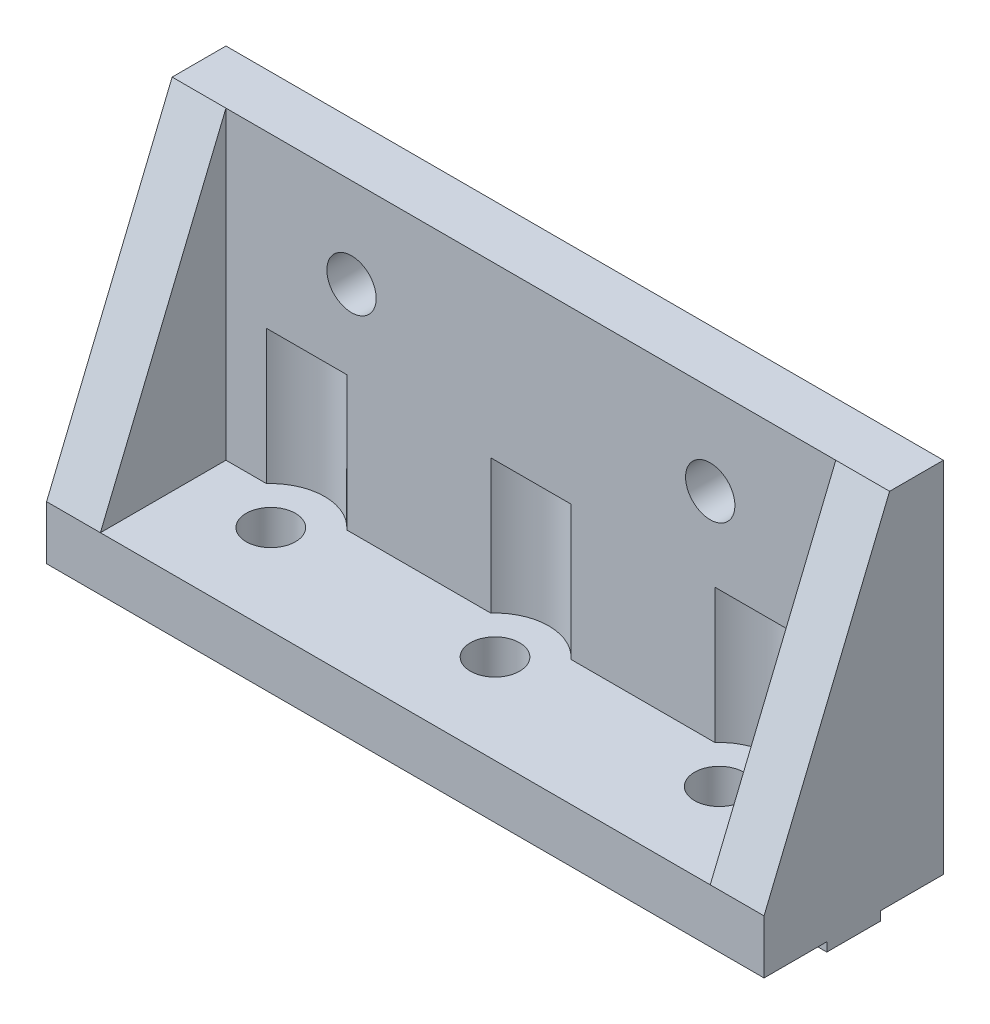
from build123d import *

# Parameters (mm, degrees)
CROQUIS1_W                 = 80
CROQUIS1_H                 = 40
SALIENTE_EXTRUIR1_DEPTH    = 20
CROQUIS2_W                 = 68
CROQUIS2_H                 = 14
CORTAR_EXTRUIR1_DEPTH      = 34
CORTAR_EXTRUIR2_DEPTH      = 80
CORTAR_EXTRUIR3_REACH      = 22
CROQUIS4_R                 = 2.75
CROQUIS8_W                 = 80
CROQUIS8_H                 = 6
SALIENTE_EXTRUIR2_DEPTH    = 1
CROQUIS5_R                 = 2.75
CORTAR_EXTRUIR6_DEPTH      = 2
CORTAR_EXTRUIR6_DEPTH_BACK = 41
CROQUIS9_R                 = 6
CORTAR_EXTRUIR8_DEPTH      = 15


with BuildPart() as part:
    # Croquis1 → Saliente-Extruir1 (new body)
    with BuildSketch(Plane.XY):
        with Locations((40, -20)):
            Rectangle(CROQUIS1_W, CROQUIS1_H)
    extrude(amount=SALIENTE_EXTRUIR1_DEPTH)

    # Croquis2 → Cortar-Extruir1 (cut)
    with BuildSketch(Plane(origin=(0, 0, 0), x_dir=(1, 0, 0), z_dir=(0, 1, 0))):
        with Locations((40, -13)):
            Rectangle(CROQUIS2_W, CROQUIS2_H)
    extrude(amount=-CORTAR_EXTRUIR1_DEPTH, mode=Mode.SUBTRACT)

    # Croquis3 → Cortar-Extruir2 (cut)
    with BuildSketch(Plane.ZY):
        Polygon((20, 0), (20, -34), (6, 0), align=None)
    extrude(amount=-CORTAR_EXTRUIR2_DEPTH, mode=Mode.SUBTRACT)

    # Croquis4 → Cortar-Extruir3 (cut, up to next)
    with BuildSketch(Plane(origin=(0, 0, 0), x_dir=(-1, 0, 0), z_dir=(0, 0, -1)), mode=Mode.PRIVATE) as cortar_extruir3_sk1:
        with Locations((-60, -10)):
            Circle(CROQUIS4_R)
    cortar_extruir3_tool1 = extrude(cortar_extruir3_sk1.sketch, amount=-CORTAR_EXTRUIR3_REACH, mode=Mode.PRIVATE) & part.part
    add(cortar_extruir3_tool1.solids().sort_by_distance((60, -10, 0))[0], mode=Mode.SUBTRACT)
    # Croquis4 → Cortar-Extruir3 (cut, up to next)
    with BuildSketch(Plane(origin=(0, 0, 0), x_dir=(-1, 0, 0), z_dir=(0, 0, -1)), mode=Mode.PRIVATE) as cortar_extruir3_sk2:
        with Locations((-20, -10)):
            Circle(CROQUIS4_R)
    cortar_extruir3_tool2 = extrude(cortar_extruir3_sk2.sketch, amount=-CORTAR_EXTRUIR3_REACH, mode=Mode.PRIVATE) & part.part
    add(cortar_extruir3_tool2.solids().sort_by_distance((20, -10, 0))[0], mode=Mode.SUBTRACT)

    # Croquis8 → Saliente-Extruir2 (add)
    with BuildSketch(Plane.XZ.offset(40)):
        with Locations((40, 10)):
            Rectangle(CROQUIS8_W, CROQUIS8_H)
    extrude(amount=SALIENTE_EXTRUIR2_DEPTH)

    # Croquis5 → Cortar-Extruir6 (cut, two sides)
    with BuildSketch(Plane.XZ.offset(40)) as cortar_extruir6_sk:
        with Locations((15, 10)):
            Circle(CROQUIS5_R)
        with Locations((40, 10)):
            Circle(CROQUIS5_R)
        with Locations((65, 10)):
            Circle(CROQUIS5_R)
    extrude(amount=CORTAR_EXTRUIR6_DEPTH, mode=Mode.SUBTRACT)
    extrude(cortar_extruir6_sk.sketch, amount=-CORTAR_EXTRUIR6_DEPTH_BACK, mode=Mode.SUBTRACT)

    # Croquis9 → Cortar-Extruir8 (cut)
    with BuildSketch(Plane(origin=(0, -34, 0), x_dir=(1, 0, 0), z_dir=(0, 1, 0))):
        with Locations((15, -10)):
            Circle(CROQUIS9_R)
        with Locations((40, -10)):
            Circle(CROQUIS9_R)
        with Locations((65, -10)):
            Circle(CROQUIS9_R)
    extrude(amount=CORTAR_EXTRUIR8_DEPTH, mode=Mode.SUBTRACT)


solid = part.part
